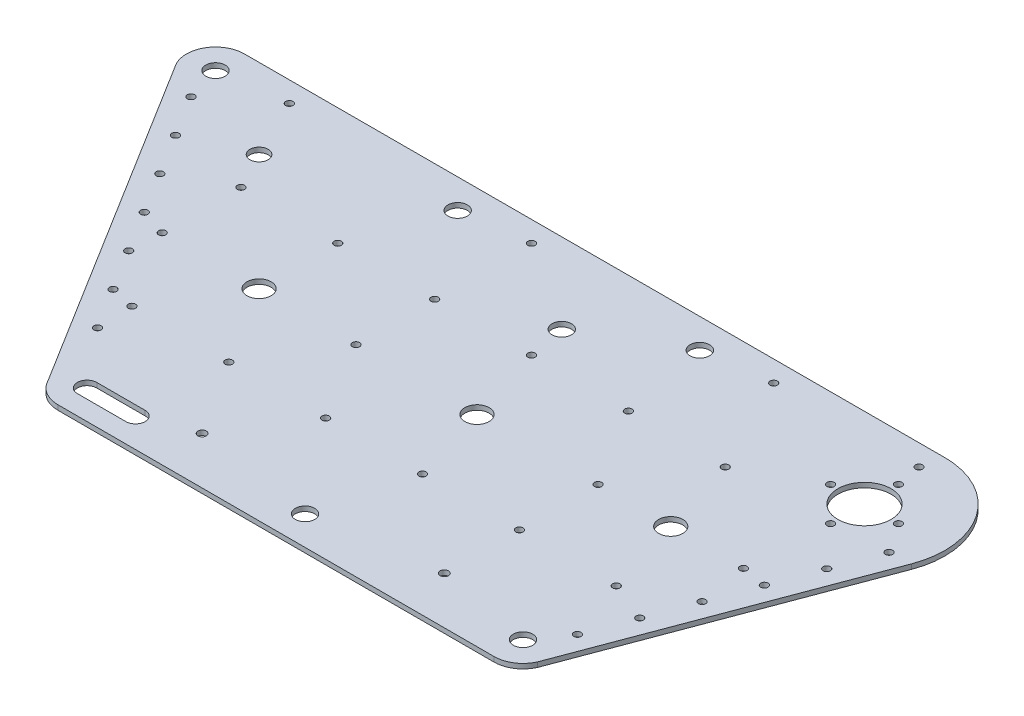
from build123d import *

# Parameters (mm, degrees)
SKETCH2_R           = 11
SKETCH2_R_2         = 5
SKETCH2_R_3         = 1.5
SKETCH2_R_4         = 4
SKETCH2_R_5         = 1.75
SKETCH2_RX          = 4
SKETCH2_RY          = 4
SKETCH2_RX_2        = 1.5
SKETCH2_RY_2        = 1.499925
SKETCH2_RX_3        = 3.75
SKETCH2_RY_3        = 3.7498125
BOSS_EXTRUDE1_DEPTH = 2


with BuildPart() as part:
    # Sketch2 → Boss-Extrude1 (new body)
    with BuildSketch(Plane(origin=(0, 0, 0), x_dir=(1, 0, 0), z_dir=(0, 1, 0))):
        with BuildLine():
            Line((-106.00499968, 144.943614194), (182.962816245, 145.197156615))
            add(Edge.make_bspline(
                [(214.069631291, 100.332253712), (230.927799732, 145.239327045), (182.962816245, 145.197156615)],
                knots=[4.353250182, 4.353250182, 4.353250182, 6.284064455, 6.284064455, 6.284064455], degree=2, weights=[1, 0.569082143, 1]))
            Line((214.069631291, 100.332253712), (171.90071668, -12.000000001))
            add(Edge.make_bspline(
                [(160.992350179, -19), (168.692373591, -19.000128232), (171.90071668, -12.000000001)],
                knots=[3.141576001, 3.141576001, 3.141576001, 4.282613549, 4.282613549, 4.282613549], degree=2, weights=[1, 0.841620915, 1]))
            Line((160.992350179, -19), (-18.998606102, -18.99996049))
            add(Edge.make_bspline(
                [(-29.699861268, -12.428586042), (-26.366669696, -18.999958873), (-18.998606102, -18.99996049)],
                knots=[5.181825727, 5.181825727, 5.181825727, 6.283185508, 6.283185508, 6.283185508], degree=2, weights=[1, 0.852168955, 1]))
            Line((-29.699861268, -12.428586042), (-116.08526313, 126.611232779))
            add(Edge.make_bspline(
                [(-106.00499968, 144.943614194), (-127.678824036, 144.924558741), (-116.08526313, 126.611232779)],
                knots=[0.000879148, 0.000879148, 0.000879148, 2.135198153, 2.135198153, 2.135198153], degree=2, weights=[1, 0.482613975, 1]))
        make_face()
        with Locations((182.992000002, 111.999999999)):
            Circle(SKETCH2_R, mode=Mode.SUBTRACT)
        with Locations((-18.9988, 64)):
            Circle(SKETCH2_R_2, mode=Mode.SUBTRACT)
        with Locations((70.99645, 64)):
            Circle(SKETCH2_R_2, mode=Mode.SUBTRACT)
        with Locations((150.9927, 64)):
            Circle(SKETCH2_R_2, mode=Mode.SUBTRACT)
        with Locations((-78.996040132, 136.5)):
            Circle(SKETCH2_R_3, mode=Mode.SUBTRACT)
        with Locations((20.99895, 136.5)):
            Circle(SKETCH2_R_3, mode=Mode.SUBTRACT)
        with Locations((120.99395, 136.5)):
            Circle(SKETCH2_R_3, mode=Mode.SUBTRACT)
        with Locations((180.99095, 136.5)):
            Circle(SKETCH2_R_3, mode=Mode.SUBTRACT)
        with Locations((170.332531489, 6.118627774)):
            Circle(SKETCH2_R_3, mode=Mode.SUBTRACT)
        with Locations((177.330672341, 24.854456596)):
            Circle(SKETCH2_R_3, mode=Mode.SUBTRACT)
        with Locations((184.328557385, 43.589600555)):
            Circle(SKETCH2_R_3, mode=Mode.SUBTRACT)
        with Locations((191.32646769, 62.324812144)):
            Circle(SKETCH2_R_3, mode=Mode.SUBTRACT)
        with Locations((198.324441471, 81.060193672)):
            Circle(SKETCH2_R_3, mode=Mode.SUBTRACT)
        with Locations((-38.361920415, 16.671266638)):
            Circle(SKETCH2_R_3, mode=Mode.SUBTRACT)
        with Locations((-48.916261932, 33.658786529)):
            Circle(SKETCH2_R_3, mode=Mode.SUBTRACT)
        with Locations((-59.470762984, 50.646563195)):
            Circle(SKETCH2_R_3, mode=Mode.SUBTRACT)
        with Locations((-70.02547384, 67.634677545)):
            Circle(SKETCH2_R_3, mode=Mode.SUBTRACT)
        with Locations((-80.580283096, 84.622950275)):
            Circle(SKETCH2_R_3, mode=Mode.SUBTRACT)
        with Locations((70.99665, -7)):
            Circle(SKETCH2_R_4, mode=Mode.SUBTRACT)
        with Locations((120.99395, 0.5)):
            Circle(SKETCH2_R_5, mode=Mode.SUBTRACT)
        with Locations((20.99895, 0.5)):
            Circle(SKETCH2_R_5, mode=Mode.SUBTRACT)
        with Locations(Location((-105.9945, 133), (0, 0, 180))):
            Ellipse(SKETCH2_RX, SKETCH2_RY, mode=Mode.SUBTRACT)
        with Locations(Location((160.99255, -7), (0, 0, 90))):
            Ellipse(SKETCH2_RX, SKETCH2_RY, mode=Mode.SUBTRACT)
        with Locations(Location((182.99085, 126), (0, 0, 90))):
            Ellipse(SKETCH2_RX_2, SKETCH2_RY_2, mode=Mode.SUBTRACT)
        with Locations(Location((196.99015, 112), (0, 0, 90))):
            Ellipse(SKETCH2_RX_2, SKETCH2_RY_2, mode=Mode.SUBTRACT)
        with Locations(Location((168.99155, 112), (0, 0, 90))):
            Ellipse(SKETCH2_RX_2, SKETCH2_RY_2, mode=Mode.SUBTRACT)
        with Locations(Location((182.99085, 98), (0, 0, 90))):
            Ellipse(SKETCH2_RX_2, SKETCH2_RY_2, mode=Mode.SUBTRACT)
        with Locations(Location((120.99395, 64), (0, 0, 90))):
            Ellipse(SKETCH2_RX_2, SKETCH2_RY_2, mode=Mode.SUBTRACT)
        with Locations(Location((20.99895, 64), (0, 0, 90))):
            Ellipse(SKETCH2_RX_2, SKETCH2_RY_2, mode=Mode.SUBTRACT)
        with Locations(Location((-58.99705, 64), (0, 0, 90))):
            Ellipse(SKETCH2_RX_2, SKETCH2_RY_2, mode=Mode.SUBTRACT)
        with Locations(Location((180.99095, 64), (0, 0, 90))):
            Ellipse(SKETCH2_RX_2, SKETCH2_RY_2, mode=Mode.SUBTRACT)
        with Locations(Location((60.99695, 96.5), (0, 0, 90))):
            Ellipse(SKETCH2_RX_2, SKETCH2_RY_2, mode=Mode.SUBTRACT)
        with Locations(Location((140.99295, 96.5), (0, 0, 90))):
            Ellipse(SKETCH2_RX_2, SKETCH2_RY_2, mode=Mode.SUBTRACT)
        with Locations(Location((160.99195, 31.499978192), (0, 0, 90))):
            Ellipse(SKETCH2_RX_2, SKETCH2_RY_2, mode=Mode.SUBTRACT)
        with Locations(Location((80.99595, 31.499985778), (0, 0, 90))):
            Ellipse(SKETCH2_RX_2, SKETCH2_RY_2, mode=Mode.SUBTRACT)
        with Locations(Location((-18.99905, 96.5), (0, 0, 90))):
            Ellipse(SKETCH2_RX_2, SKETCH2_RY_2, mode=Mode.SUBTRACT)
        with Locations(Location((-38.99805, 31.499994311), (0, 0, 90))):
            Ellipse(SKETCH2_RX_2, SKETCH2_RY_2, mode=Mode.SUBTRACT)
        with Locations(Location((-101.689209002, 118.598380963), (0, 0, 90))):
            Ellipse(SKETCH2_RX_2, SKETCH2_RY_2, mode=Mode.SUBTRACT)
        with Locations(Location((-91.134705429, 101.610600241), (0, 0, 90))):
            Ellipse(SKETCH2_RX_2, SKETCH2_RY_2, mode=Mode.SUBTRACT)
        with Locations(Location((205.322481122, 99.795751553), (0, 0, 90))):
            Ellipse(SKETCH2_RX_2, SKETCH2_RY_2, mode=Mode.SUBTRACT)
        with Locations(Location((20.99895, 96.5), (0, 0, 90))):
            Ellipse(SKETCH2_RX_2, SKETCH2_RY_2, mode=Mode.SUBTRACT)
        with Locations(Location((100.99495, 96.5), (0, 0, 90))):
            Ellipse(SKETCH2_RX_2, SKETCH2_RY_2, mode=Mode.SUBTRACT)
        with Locations(Location((-58.99705, 96.5), (0, 0, 90))):
            Ellipse(SKETCH2_RX_2, SKETCH2_RY_2, mode=Mode.SUBTRACT)
        with Locations(Location((0.99995, 31.499992415), (0, 0, 90))):
            Ellipse(SKETCH2_RX_2, SKETCH2_RY_2, mode=Mode.SUBTRACT)
        with Locations(Location((40.99795, 31.499988622), (0, 0, 90))):
            Ellipse(SKETCH2_RX_2, SKETCH2_RY_2, mode=Mode.SUBTRACT)
        with Locations(Location((120.99395, 31.499981037), (0, 0, 90))):
            Ellipse(SKETCH2_RX_2, SKETCH2_RY_2, mode=Mode.SUBTRACT)
        with Locations(Location((-66.99665, 112), (0, 0, 90))):
            Ellipse(SKETCH2_RX_3, SKETCH2_RY_3, mode=Mode.SUBTRACT)
        with Locations(Location((57.9973, 112), (0, 0, 180))):
            Ellipse(SKETCH2_RX, SKETCH2_RY, mode=Mode.SUBTRACT)
        with Locations(Location((-5.9995, 133), (0, 0, 90))):
            Ellipse(SKETCH2_RX, SKETCH2_RY, mode=Mode.SUBTRACT)
        with Locations(Location((93.995420809, 133), (0, 0, 180))):
            Ellipse(SKETCH2_RX, SKETCH2_RY, mode=Mode.SUBTRACT)
        with BuildLine():
            Line((-18.998603467, -3), (1.00035, -3))
            add(Edge.make_bspline(
                [(1.00035, -11), (5.00035, -11), (5.00035, -7), (5.00035, -3), (1.00035, -3)],
                knots=[3.141592654, 3.141592654, 3.141592654, 4.71238898, 4.71238898, 6.283185307, 6.283185307, 6.283185307], degree=2, weights=[1, 0.707106781, 1, 0.707106781, 1]))
            Line((1.00035, -11), (-18.998603467, -11))
            add(Edge.make_bspline(
                [(-18.998603467, -3), (-22.998556935, -3), (-22.998556935, -7), (-22.998556935, -11), (-18.998603467, -11)],
                knots=[3.141592654, 3.141592654, 3.141592654, 4.71238898, 4.71238898, 6.283185307, 6.283185307, 6.283185307], degree=2, weights=[1, 0.707106781, 1, 0.707106781, 1]))
        make_face(mode=Mode.SUBTRACT)
    extrude(amount=BOSS_EXTRUDE1_DEPTH)


solid = part.part
